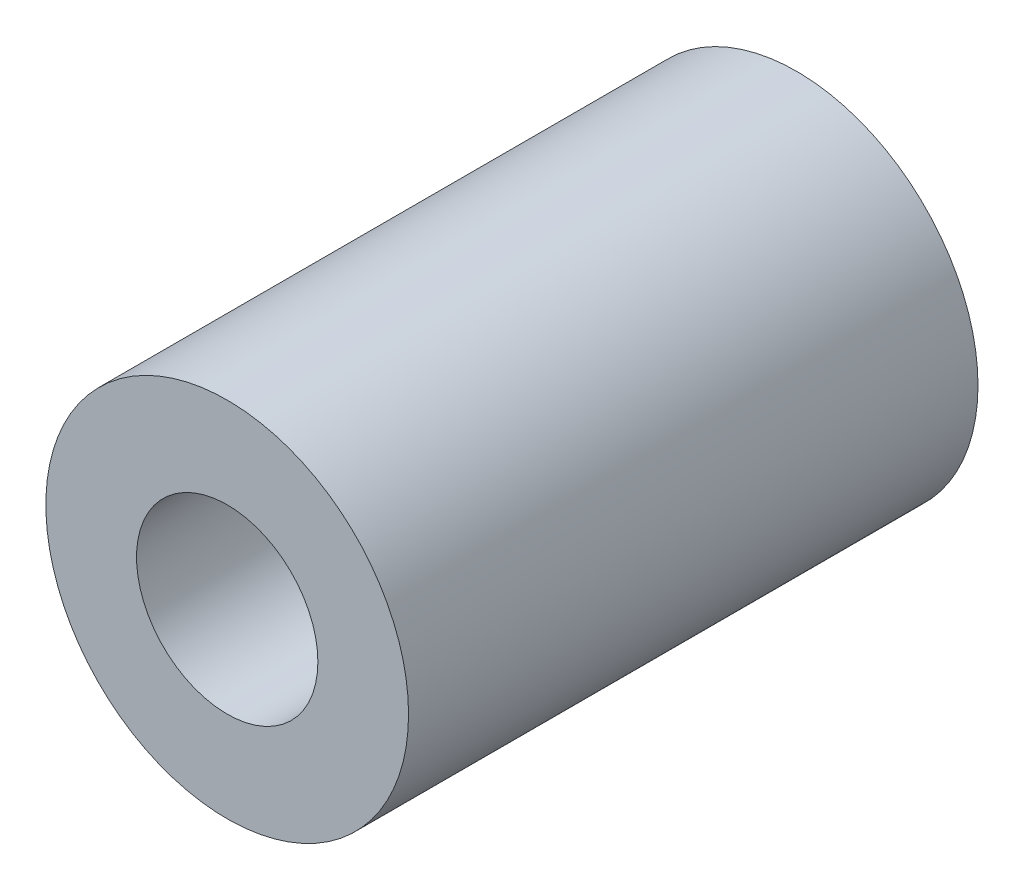
from build123d import *

# Parameters (mm, degrees)
SKETCH1_R                 = 5
BOSS_EXTRUDE1_DEPTH       = 15.7
F_5_0MM_DOWEL_HOLE1_D     = 5
F_5_0MM_DOWEL_HOLE1_DEPTH = 15.7


with BuildPart() as part:
    # Sketch1 → Boss-Extrude1 (new body)
    with BuildSketch(Plane.XY):
        Circle(SKETCH1_R)
    extrude(amount=BOSS_EXTRUDE1_DEPTH)

    # Ø5.0mm Dowel Hole1
    with Locations(Plane.XY.offset(15.7)):
        with Locations((0, 0)):
            Hole(F_5_0MM_DOWEL_HOLE1_D / 2, depth=F_5_0MM_DOWEL_HOLE1_DEPTH)


solid = part.part
